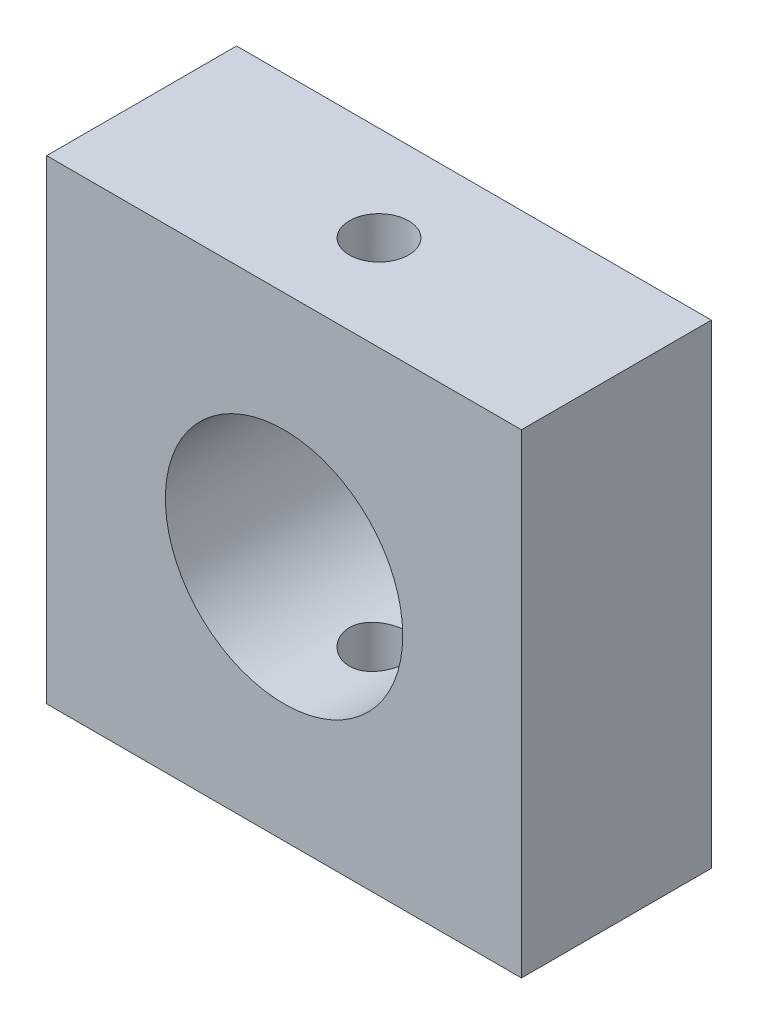
from build123d import *

# Parameters (mm, degrees)
SKETCH1_W           = 20
SKETCH1_H           = 20
SKETCH1_R           = 5
BOSS_EXTRUDE1_DEPTH = 8
SKETCH3_R           = 1.25
CUT_EXTRUDE1_DEPTH  = 20


with BuildPart() as part:
    # Sketch1 → Boss-Extrude1 (new body)
    with BuildSketch(Plane.XY):
        with Locations((50, -50)):
            Rectangle(SKETCH1_W, SKETCH1_H)
        with Locations((50, -50)):
            Circle(SKETCH1_R, mode=Mode.SUBTRACT)
    extrude(amount=BOSS_EXTRUDE1_DEPTH)

    # Sketch3 → Cut-Extrude1 (cut)
    with BuildSketch(Plane(origin=(0, -60, 0), x_dir=(-1, 0, 0), z_dir=(0, -1, 0))):
        with Locations((-50, -4)):
            Circle(SKETCH3_R)
    extrude(amount=-CUT_EXTRUDE1_DEPTH, mode=Mode.SUBTRACT)


solid = part.part
